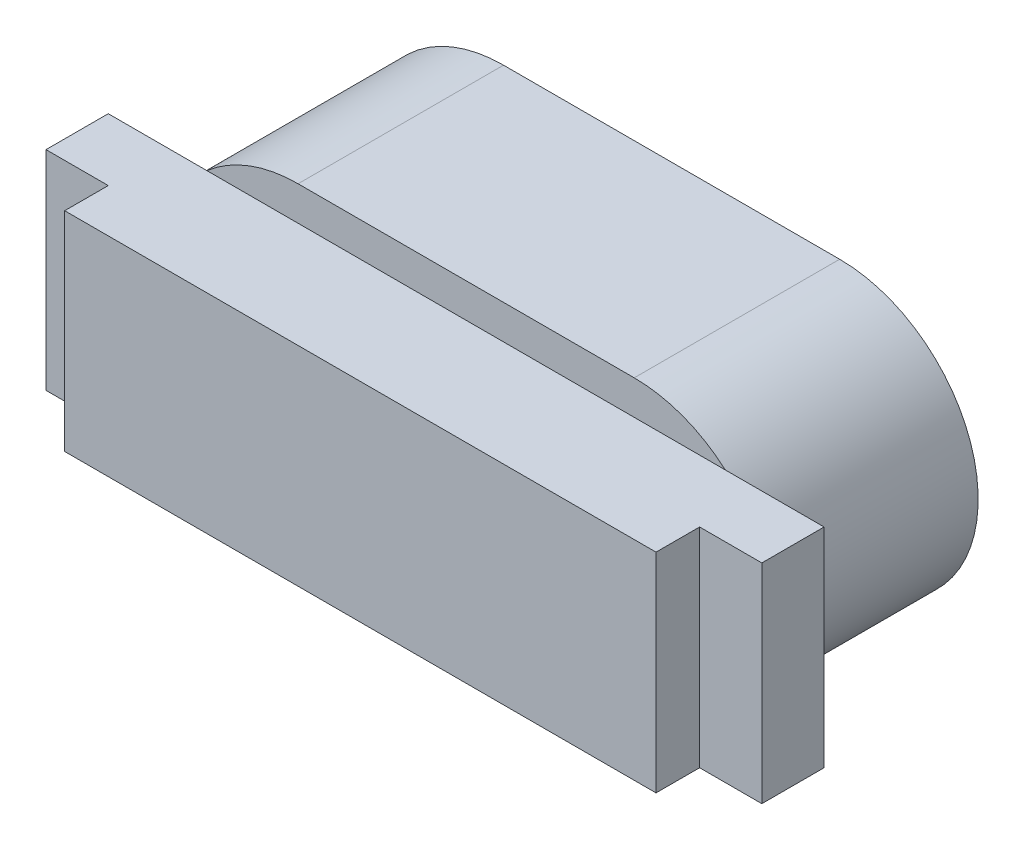
from build123d import *

# Parameters (mm, degrees)
BOSS_EXTRU_1_DEPTH = 3.3
ESQUISSE4_W        = 11.5
ESQUISSE4_H        = 3.35
BOSS_EXTRU_2_DEPTH = 1
ESQUISSE5_W        = 9.5
ESQUISSE5_H        = 3.35
BOSS_EXTRU_3_DEPTH = 0.7


with BuildPart() as part:
    # Esquisse3 → Boss.-Extru.1 (new body)
    with BuildSketch(Plane.XY):
        with BuildLine():
            Line((-2.7, 2.225), (2.7, 2.225))
            ThreePointArc((2.7, 2.225), (4.925, 0), (2.7, -2.225))
            Line((2.7, -2.225), (-2.7, -2.225))
            ThreePointArc((-2.7, -2.225), (-4.925, 0), (-2.7, 2.225))
        make_face()
    extrude(amount=BOSS_EXTRU_1_DEPTH)

    # Esquisse4 → Boss.-Extru.2 (add)
    with BuildSketch(Plane.XY.offset(3.3)):
        Rectangle(ESQUISSE4_W, ESQUISSE4_H)
    extrude(amount=BOSS_EXTRU_2_DEPTH)

    # Esquisse5 → Boss.-Extru.3 (add)
    with BuildSketch(Plane.XY.offset(4.3)):
        Rectangle(ESQUISSE5_W, ESQUISSE5_H)
    extrude(amount=BOSS_EXTRU_3_DEPTH)


solid = part.part
